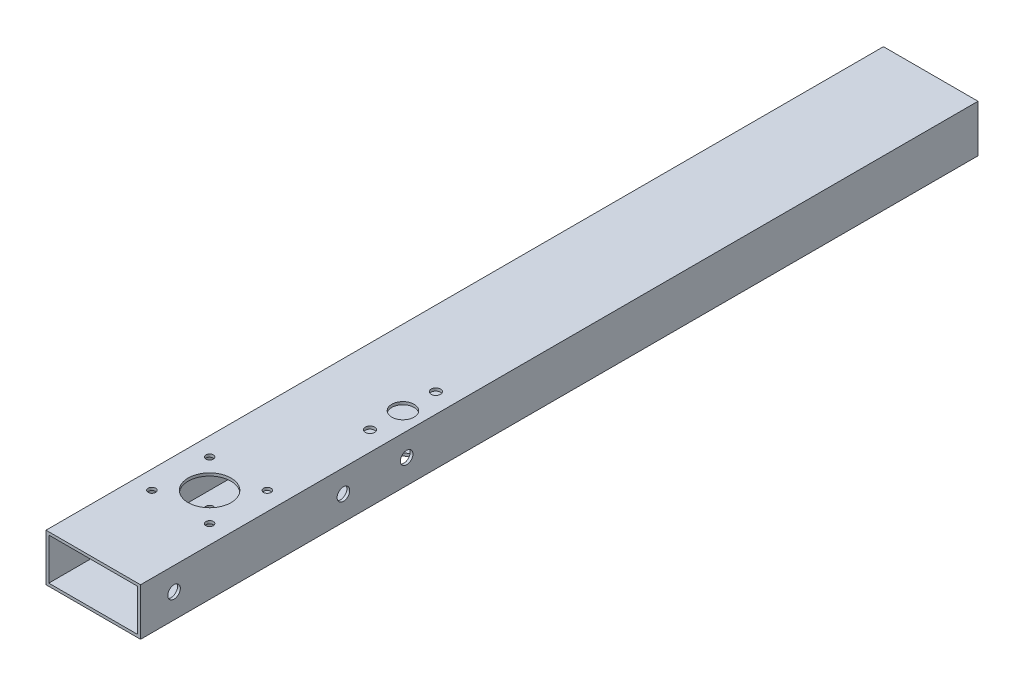
from build123d import *

# Parameters (mm, degrees)
CROQUIS1_W                    = 50.8
CROQUIS1_H                    = 25.4
CROQUIS1_W_2                  = 47.8
CROQUIS1_H_2                  = 22.4
SALIENTE_EXTRUIR1_DEPTH       = 450
CROQUIS2_R                    = 11.5
CROQUIS2_R_2                  = 2
CORTAR_EXTRUIR1_DEPTH         = 26
TALADRO_DE_MARGEN_PARA_1_41_D = 6.7564
CROQUIS5_R                    = 6
CROQUIS5_R_2                  = 2.5
CORTAR_EXTRUIR2_DEPTH         = 25.4


with BuildPart() as part:
    # Croquis1 → Saliente-Extruir1 (new body)
    with BuildSketch(Plane.XY):
        Rectangle(CROQUIS1_W, CROQUIS1_H)
        Rectangle(CROQUIS1_W_2, CROQUIS1_H_2, mode=Mode.SUBTRACT)
    extrude(amount=SALIENTE_EXTRUIR1_DEPTH)

    # Croquis2 → Cortar-Extruir1 (cut)
    with BuildSketch(Plane(origin=(0, -12.7, 0), x_dir=(-1, 0, 0), z_dir=(0, -1, 0))):
        with Locations((0, -387.5)):
            Circle(CROQUIS2_R)
        with Locations((15.5, -403)):
            Circle(CROQUIS2_R_2)
        with Locations((-15.5, -403)):
            Circle(CROQUIS2_R_2)
        with Locations((-15.5, -372)):
            Circle(CROQUIS2_R_2)
        with Locations((15.5, -372)):
            Circle(CROQUIS2_R_2)
    extrude(amount=-CORTAR_EXTRUIR1_DEPTH, mode=Mode.SUBTRACT)

    # Taladro de margen para 1/41 (through all)
    with Locations(Plane(origin=(-25.4, 197.888619806, 162.989101594), x_dir=(0, -1, 0), z_dir=(-1, 0, 0))):
        with Locations((197.488619806, 269.010898406), (197.488619806, 178.010898406), (197.488619806, 144.010898406), (572.888619806, 144.010898406), (572.888619806, 178.010898406), (572.888619806, 269.010898406)):
            Hole(TALADRO_DE_MARGEN_PARA_1_41_D / 2)

    # Croquis5 → Cortar-Extruir2 (cut)
    with BuildSketch(Plane.XZ.offset(12.7)):
        with Locations((14.9, 298.5)):
            Circle(CROQUIS5_R)
        with Locations((14.9, 316.2)):
            Circle(CROQUIS5_R_2)
        with Locations((14.9, 280.8)):
            Circle(CROQUIS5_R_2)
    extrude(amount=-CORTAR_EXTRUIR2_DEPTH, mode=Mode.SUBTRACT)


solid = part.part
